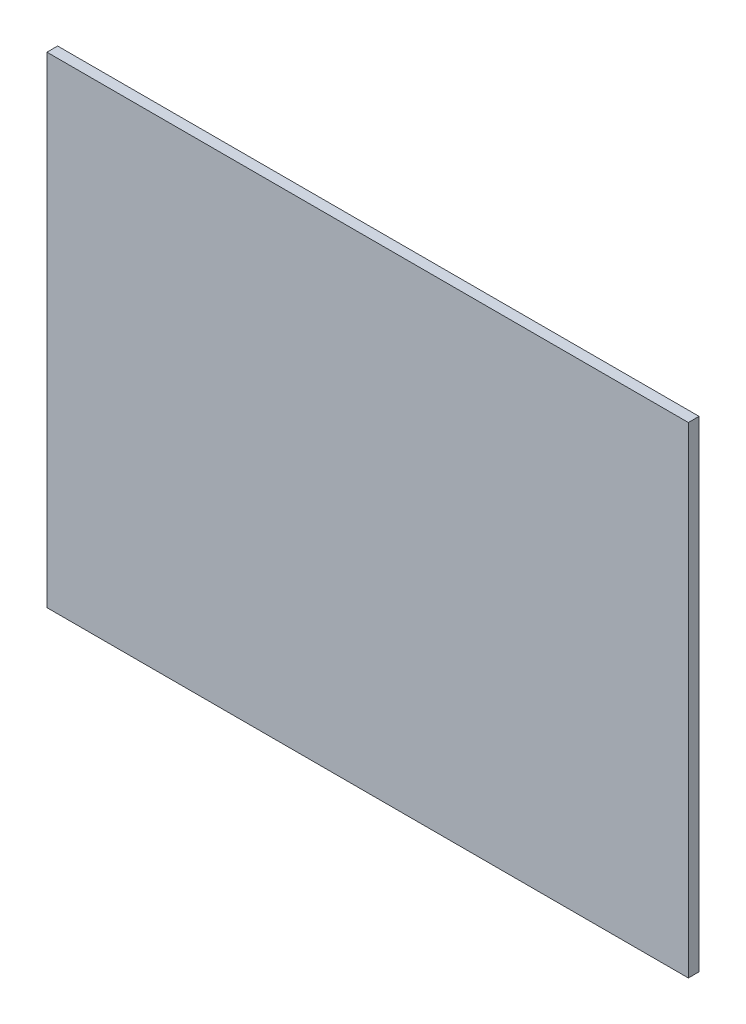
from build123d import *

# Parameters (mm, degrees)
CROQUIS1_W              = 600
CROQUIS1_H              = 450
SALIENTE_EXTRUIR1_DEPTH = 10


with BuildPart() as part:
    # Croquis1 → Saliente-Extruir1 (new body)
    with BuildSketch(Plane.XY):
        with Locations((238.198216155, -182.030121655)):
            Rectangle(CROQUIS1_W, CROQUIS1_H)
    extrude(amount=SALIENTE_EXTRUIR1_DEPTH)


solid = part.part
